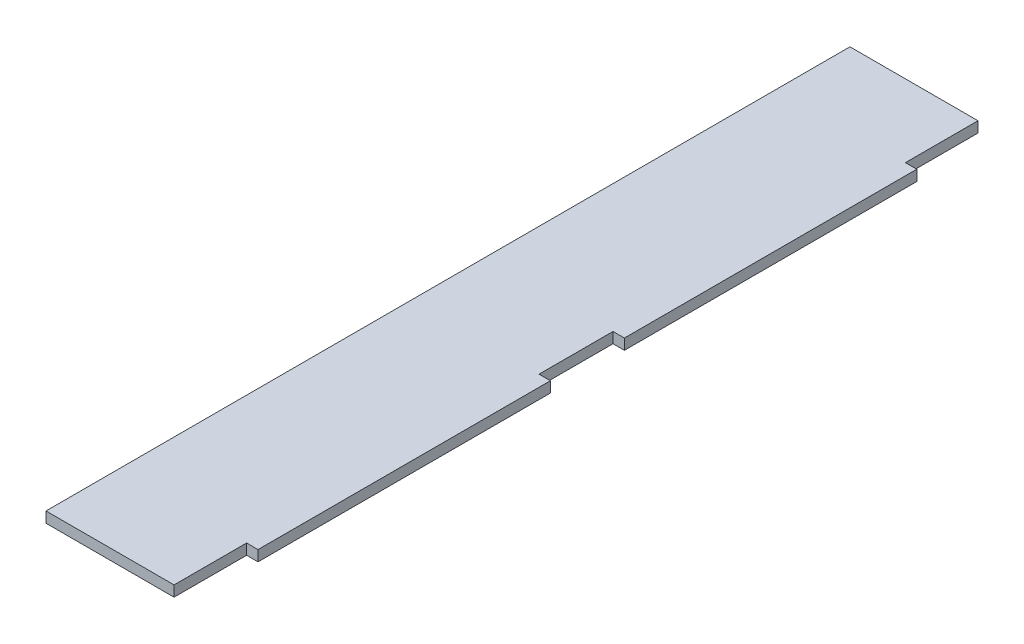
from build123d import *

# Parameters (mm, degrees)
BOSS_EXTRUDE1_DEPTH = 1.5


with BuildPart() as part:
    # Sketch1 → Boss-Extrude1 (new body)
    with BuildSketch(Plane(origin=(0, 0, 0), x_dir=(1, 0, 0), z_dir=(0, 1, 0))):
        Polygon((18, 113), (18, 102.8), (19.6, 102.8), (19.6, 61.7), (18, 61.7), (18, 51.3), (19.6, 51.3), (19.6, 10.2), (18, 10.2), (18, 0), (0, 0), (0, 113), align=None)
    extrude(amount=BOSS_EXTRUDE1_DEPTH)


solid = part.part
